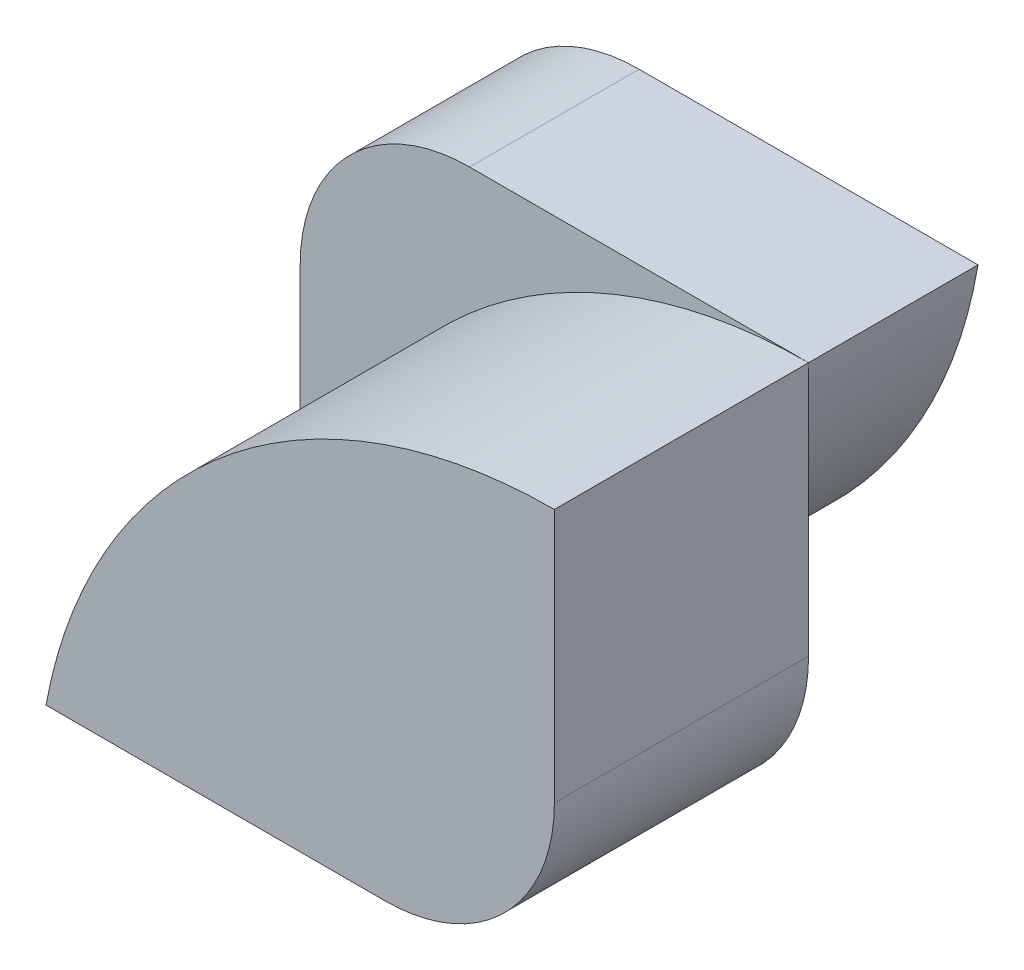
from build123d import *

# Parameters (mm, degrees)
BOSS_EXTRUDE1_DEPTH = 10
BOSS_EXTRUDE2_DEPTH = 15


with BuildPart() as part:
    # Sketch1 → Boss-Extrude1 (new body)
    with BuildSketch(Plane.XY):
        with BuildLine():
            Line((0, 0), (-20, 0))
            ThreePointArc((-20, 0), (-27.071067812, -2.928932188), (-30, -10))
            Line((-30, -10), (-30, -25))
            ThreePointArc((-30, -25), (-10.375361639, -18.049566033), (0, 0))
        make_face()
    extrude(amount=BOSS_EXTRUDE1_DEPTH)

    # Sketch2 → Boss-Extrude2 (add)
    with BuildSketch(Plane.XY.offset(10)):
        with BuildLine():
            Line((0, 0), (0, -15))
            ThreePointArc((0, -15), (-2.928932188, -22.071067812), (-10, -25))
            Line((-10, -25), (-30, -25))
            ThreePointArc((-30, -25), (-19.52562419, -7.069250972), (0, 0))
        make_face()
    extrude(amount=BOSS_EXTRUDE2_DEPTH)


solid = part.part
